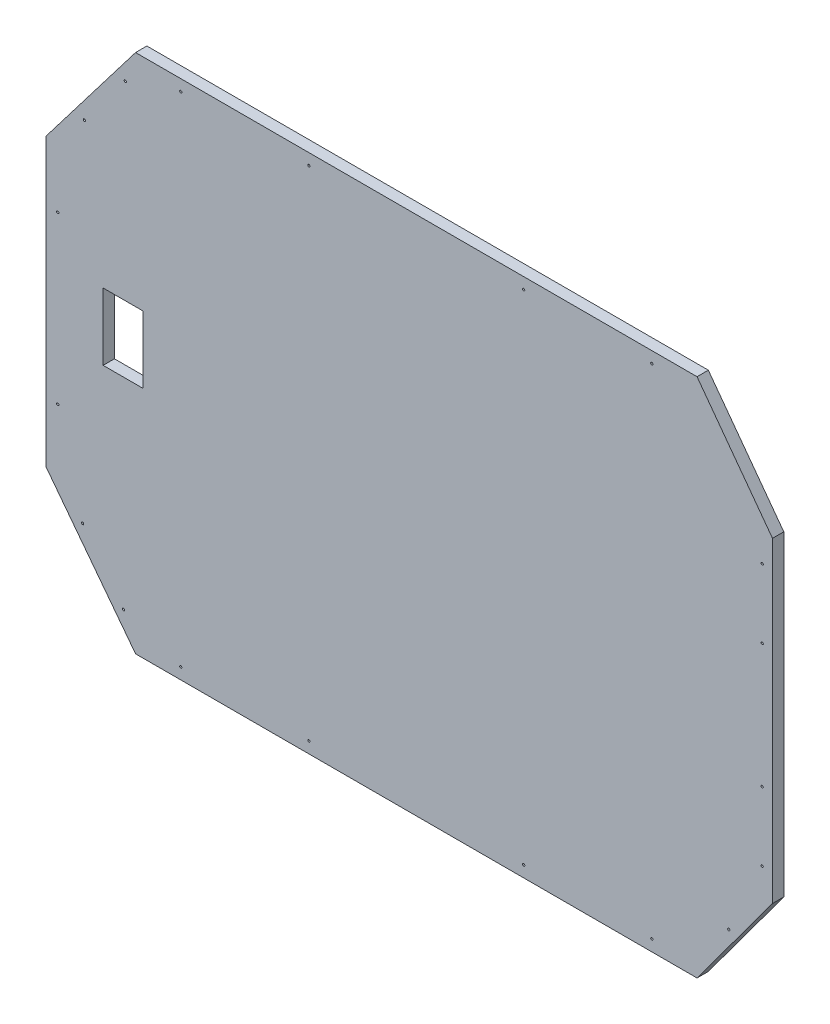
from build123d import *

# Parameters (mm, degrees)
BOSS_EXTRUDE1_DEPTH     = 15
SKETCH9_R               = 1.5
CUT_EXTRUDE1_DEPTH      = 1
CUT_EXTRUDE1_DEPTH_BACK = 16
SKETCH10_W              = 52.6
SKETCH10_H              = 88.9
CUT_EXTRUDE2_DEPTH      = 16


with BuildPart() as part:
    # Sketch2 → Boss-Extrude1 (new body)
    with BuildSketch(Plane.XY):
        Polygon((0, 500.68043587), (118.58, 345.487717935), (863.58, 345.487717935), (963.71, 481.146537036), (963.71, 900.804334703), (863.58, 1036.463153804), (118.58, 1036.463153804), (0, 881.27043587), align=None)
    extrude(amount=BOSS_EXTRUDE1_DEPTH)

    # Sketch9 → Cut-Extrude1 (cut, two sides)
    with BuildSketch(Plane(origin=(0, 0, 0), x_dir=(-1, 0, 0), z_dir=(0, 0, -1))) as cut_extrude1_sk:
        with Locations((-803.58, 1021.463153804)):
            Circle(SKETCH9_R)
        with Locations((-633.58, 1021.463153804)):
            Circle(SKETCH9_R)
        with Locations((-348.58, 1021.463153804)):
            Circle(SKETCH9_R)
        with Locations((-178.58, 1021.463153804)):
            Circle(SKETCH9_R)
        with Locations((-178.58, 360.487717935)):
            Circle(SKETCH9_R)
        with Locations((-348.58, 360.487717935)):
            Circle(SKETCH9_R)
        with Locations((-633.58, 360.487717935)):
            Circle(SKETCH9_R)
        with Locations((-803.58, 360.487717935)):
            Circle(SKETCH9_R)
        with Locations((-905.654330921, 422.269736472)):
            Circle(SKETCH9_R)
        with Locations((-950.019491684, 517.22090145)):
            Circle(SKETCH9_R)
        with Locations((-950.019491684, 864.74090145)):
            Circle(SKETCH9_R)
        with Locations((-950.019491684, 773.32689058)):
            Circle(SKETCH9_R)
        with Locations((-950.019491684, 608.634912319)):
            Circle(SKETCH9_R)
        with BuildLine():
            ThreePointArc((-49.79686308, 923.634087088), (-49.502283169, 925.734854252), (-51.603050333, 926.029434163))
            ThreePointArc((-51.603050333, 926.029434163), (-51.897630244, 923.928666999), (-49.79686308, 923.634087088))
        make_face()
        with BuildLine():
            ThreePointArc((-103.982480668, 995.494499324), (-103.687900757, 997.595266487), (-105.78866792, 997.889846398))
            ThreePointArc((-105.78866792, 997.889846398), (-106.083247831, 995.789079234), (-103.982480668, 995.494499324))
        make_face()
        with BuildLine():
            ThreePointArc((-15.328698966, 802.77043587), (-16.828698966, 801.27043587), (-15.328698966, 799.77043587))
            ThreePointArc((-15.328698966, 799.77043587), (-13.828698966, 801.27043587), (-15.328698966, 802.77043587))
        make_face()
        with BuildLine():
            ThreePointArc((-15.328698966, 582.18043587), (-16.828698966, 580.68043587), (-15.328698966, 579.18043587))
            ThreePointArc((-15.328698966, 579.18043587), (-13.828698966, 580.68043587), (-15.328698966, 582.18043587))
        make_face()
        with BuildLine():
            ThreePointArc((-49.199469581, 459.109041803), (-47.098702418, 459.403621714), (-47.393282329, 461.504388877))
            ThreePointArc((-47.393282329, 461.504388877), (-49.494049492, 461.209808967), (-49.199469581, 459.109041803))
        make_face()
        with BuildLine():
            ThreePointArc((-103.385087169, 387.248629567), (-101.284320005, 387.543209478), (-101.578899916, 389.643976642))
            ThreePointArc((-101.578899916, 389.643976642), (-103.67966708, 389.349396731), (-103.385087169, 387.248629567))
        make_face()
    extrude(amount=CUT_EXTRUDE1_DEPTH, mode=Mode.SUBTRACT)
    extrude(cut_extrude1_sk.sketch, amount=-CUT_EXTRUDE1_DEPTH_BACK, mode=Mode.SUBTRACT)

    # Sketch10 → Cut-Extrude2 (cut, through all)
    with BuildSketch(Plane(origin=(0, 0, 0), x_dir=(-1, 0, 0), z_dir=(0, 0, -1))):
        with Locations((-101.850001448, 699.944225973)):
            Rectangle(SKETCH10_W, SKETCH10_H)
    extrude(amount=-CUT_EXTRUDE2_DEPTH, mode=Mode.SUBTRACT)


solid = part.part
